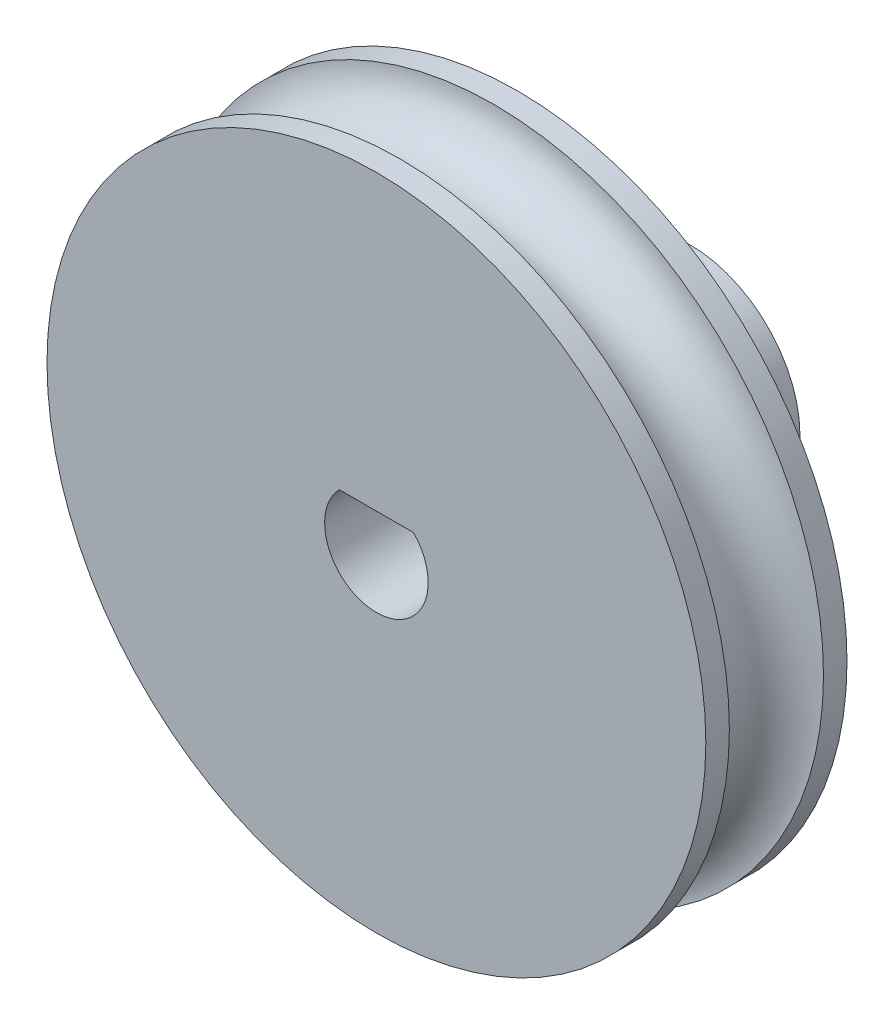
from build123d import *

# Parameters (mm, degrees)
CORTAR_EXTRUIR1_DEPTH = 11
CORTAR_EXTRUIR2_DEPTH = 10


with BuildPart() as part:
    # Croquis1 → Revolución1 (revolve)
    with BuildSketch(Plane(origin=(0, 0, 0), x_dir=(0, 0, -1), z_dir=(1, 0, 0))):
        with BuildLine():
            Line((0, 0), (0, 10.5))
            Line((0, 10.5), (0.75, 10.5))
            ThreePointArc((0.75, 10.5), (2.25, 9), (3.75, 10.5))
            Line((3.75, 10.5), (4.5, 10.5))
            Line((4.5, 10.5), (4.5, 3.5))
            Line((4.5, 3.5), (10, 3.5))
            Line((10, 3.5), (10, 0))
            Line((10, 0), (0, 0))
        make_face()
    revolve(axis=Axis((0, 0, 0), (0, 0, -1)))

    # Croquis2 → Cortar-Extruir1 (cut, through all)
    with BuildSketch(Plane(origin=(0, 0, -10), x_dir=(-1, 0, 0), z_dir=(0, 0, -1))):
        with BuildLine():
            Line((-1.161895004, 1.1), (1.161895004, 1.1))
            ThreePointArc((1.161895004, 1.1), (0, -1.6), (-1.161895004, 1.1))
        make_face()
    extrude(amount=-CORTAR_EXTRUIR1_DEPTH, mode=Mode.SUBTRACT)

    # Croquis3 → Cortar-Extruir2 (cut)
    with BuildSketch(Plane(origin=(0, 0, -10), x_dir=(-1, 0, 0), z_dir=(0, 0, -1))):
        with BuildLine():
            Line((-1.183215957, 1.15), (1.183215957, 1.15))
            ThreePointArc((1.183215957, 1.15), (0, -1.65), (-1.183215957, 1.15))
        make_face()
    extrude(amount=-CORTAR_EXTRUIR2_DEPTH, mode=Mode.SUBTRACT)


solid = part.part
